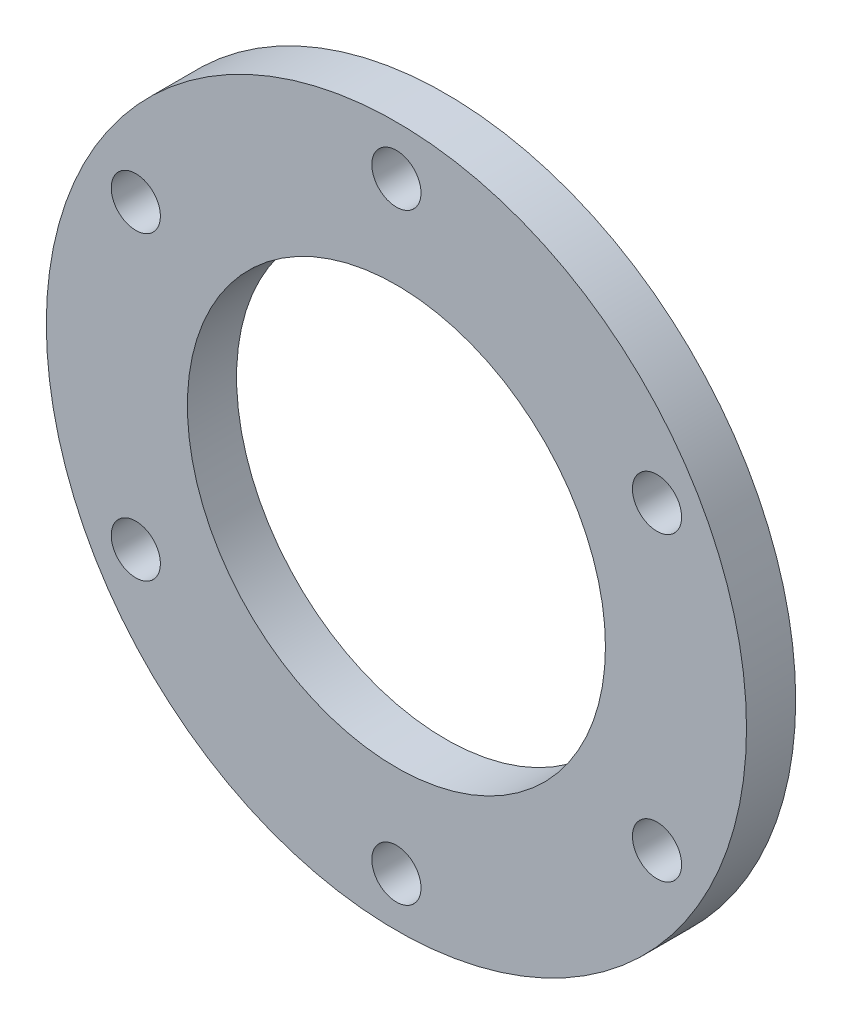
from build123d import *

# Parameters (mm, degrees)
SKETCH1_R           = 45.2
SKETCH1_R_2         = 26.9875
SKETCH1_R_3         = 3.175
BOSS_EXTRUDE1_DEPTH = 6.35


with BuildPart() as part:
    # Sketch1 → Boss-Extrude1 (new body)
    with BuildSketch(Plane.XY):
        Circle(SKETCH1_R)
        Circle(SKETCH1_R_2, mode=Mode.SUBTRACT)
        with Locations((0, 38.8500112)):
            Circle(SKETCH1_R_3, mode=Mode.SUBTRACT)
        with Locations((33.645096637, 19.4250056)):
            Circle(SKETCH1_R_3, mode=Mode.SUBTRACT)
        with Locations((33.645096637, -19.4250056)):
            Circle(SKETCH1_R_3, mode=Mode.SUBTRACT)
        with Locations((0, -38.8500112)):
            Circle(SKETCH1_R_3, mode=Mode.SUBTRACT)
        with Locations((-33.645096637, -19.4250056)):
            Circle(SKETCH1_R_3, mode=Mode.SUBTRACT)
        with Locations((-33.645096637, 19.4250056)):
            Circle(SKETCH1_R_3, mode=Mode.SUBTRACT)
    extrude(amount=BOSS_EXTRUDE1_DEPTH)


solid = part.part
